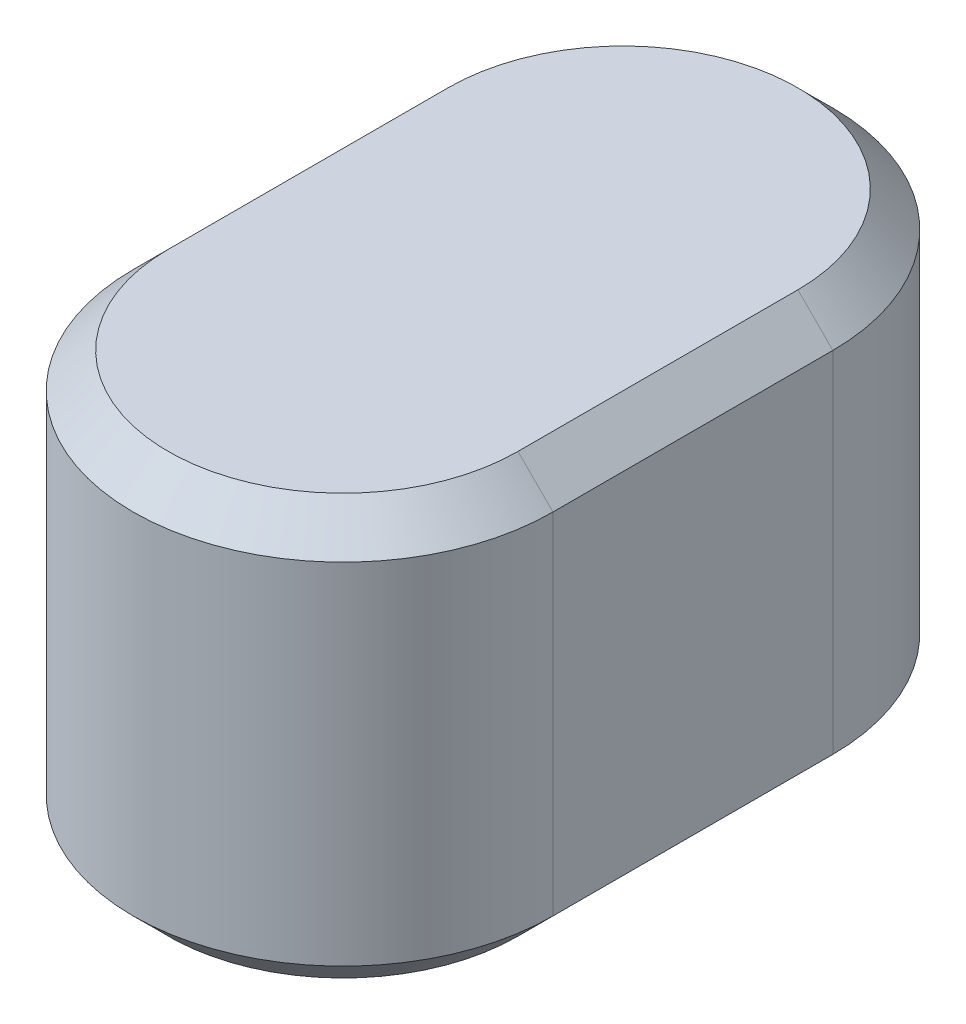
from build123d import *

# Parameters (mm, degrees)
BOSS_EXTRUDE1_DEPTH = 12
CHAMFER1_SIZE       = 1


with BuildPart() as part:
    # Sketch1 → Boss-Extrude1 (new body)
    with BuildSketch(Plane(origin=(0, 0, 0), x_dir=(1, 0, 0), z_dir=(0, 1, 0))):
        with BuildLine():
            Line((6, 0), (6, 8))
            ThreePointArc((6, 8), (0, 14), (-6, 8))
            Line((-6, 8), (-6, 0))
            ThreePointArc((-6, 0), (0, -6), (6, 0))
        make_face()
    extrude(amount=BOSS_EXTRUDE1_DEPTH)

    # Chamfer1
    chamfer1_edges = [part.edges().sort_by_distance(p)[0] for p in [
        (0, 12, -14),
        (-6, 12, -4),
        (0, 12, 6),
        (-6, 0, -4),
        (0, 0, -14),
        (6, 0, -4),
        (0, 0, 6),
        (6, 12, -4),
    ]]
    chamfer(chamfer1_edges, length=CHAMFER1_SIZE)


solid = part.part
